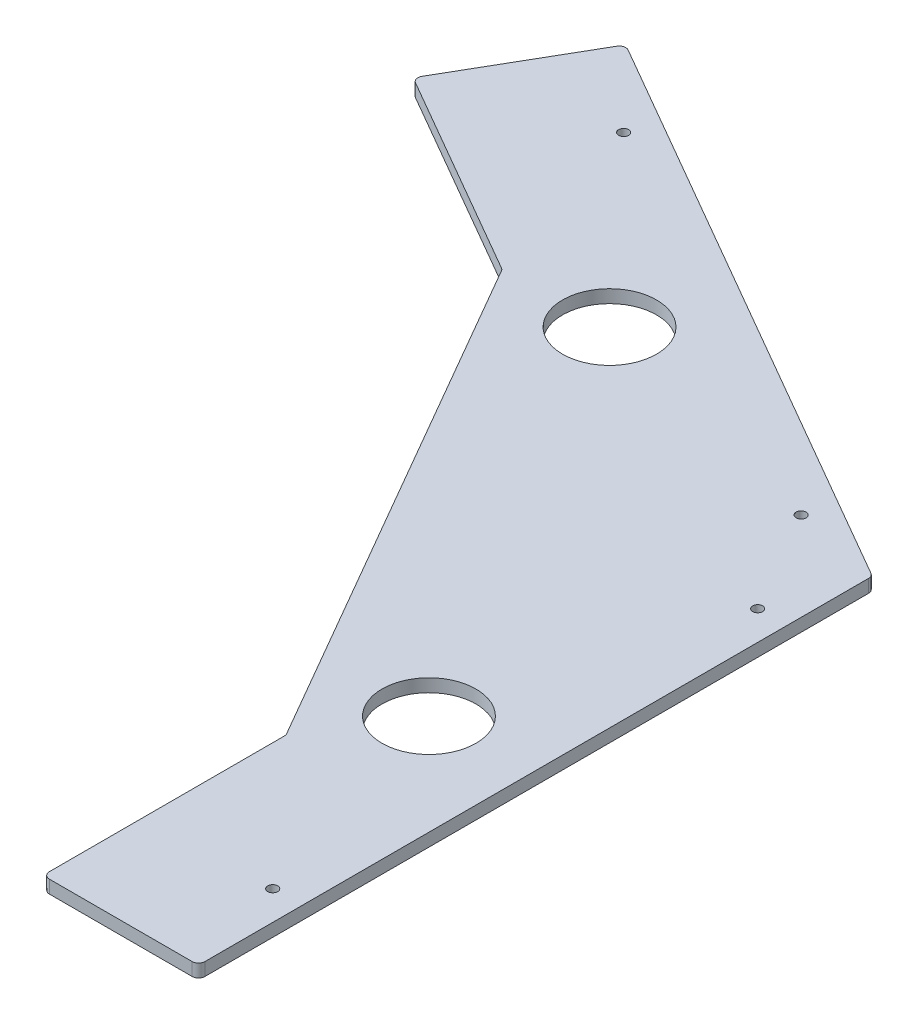
from build123d import *

# Parameters (mm, degrees)
SKETCH1_R           = 23.01875
SKETCH1_R_2         = 2.45745
BOSS_EXTRUDE1_DEPTH = 6.35
FILLET1_R           = 3.175


with BuildPart() as part:
    # Sketch1 → Boss-Extrude1 (new body)
    with BuildSketch(Plane(origin=(0, 0, 0), x_dir=(1, 0, 0), z_dir=(0, 1, 0))):
        Polygon((0, 0), (0, 329.955678842), (-285.75, 494.933518263), (-323.85, 428.942382494), (-220.760110958, 369.423407305), (-76.2, 119.037950379), (-76.2, 0), align=None)
        with Locations((-49.2125, 162.06103122)):
            Circle(SKETCH1_R, mode=Mode.SUBTRACT)
        with Locations((-170.00728, 371.283727469)):
            Circle(SKETCH1_R, mode=Mode.SUBTRACT)
        with Locations((-14.2875, 50.607868786)):
            Circle(SKETCH1_R_2, mode=Mode.SUBTRACT)
        with Locations((-14.2875, 288.082628786)):
            Circle(SKETCH1_R_2, mode=Mode.SUBTRACT)
        with Locations((-43.406875082, 338.518865913)):
            Circle(SKETCH1_R_2, mode=Mode.SUBTRACT)
        with Locations((-249.06605, 457.256245913)):
            Circle(SKETCH1_R_2, mode=Mode.SUBTRACT)
    extrude(amount=BOSS_EXTRUDE1_DEPTH)

    # Fillet1
    fillet1_edges = [part.edges().sort_by_distance(p)[0] for p in [
        (-76.2, 3.175, 0),
        (-76.2, 3.175, -119.037950379),
        (-220.760110958, 3.175, -369.423407305),
        (-323.85, 3.175, -428.942382494),
        (-285.75, 3.175, -494.933518263),
        (0, 3.175, -329.955678842),
        (0, 3.175, 0),
    ]]
    fillet(fillet1_edges, radius=FILLET1_R)


solid = part.part
